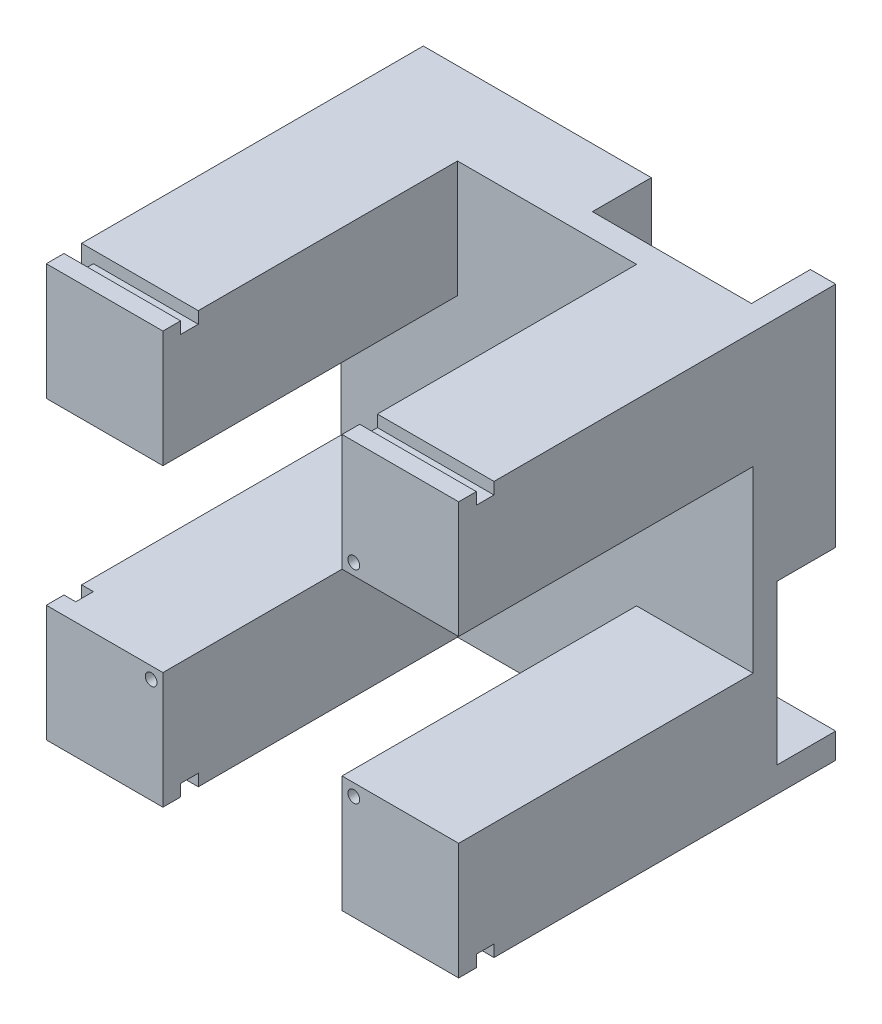
from build123d import *

# Parameters (mm, degrees)
ESQUISSE1_W                  = 70
ESQUISSE1_H                  = 70
BOSS_EXTRU_1_DEPTH           = 64
ESQUISSE2_W                  = 30.4
ESQUISSE2_H                  = 19.8
ESQUISSE2_H_2                = 30.4
ESQUISSE2_W_2                = 19.8
ENL_V_MAT_EXTRU_1_DEPTH      = 50
ESQUISSE5_W                  = 3
ESQUISSE5_H                  = 2
ENL_V_MAT_EXTRU_3_DEPTH      = 71
ESQUISSE6_W                  = 2
ESQUISSE6_H                  = 3
ENL_V_MAT_EXTRU_4_DEPTH      = 71
ESQUISSE7_R                  = 1
ENL_V_MAT_EXTRU_5_DEPTH      = 65
ENL_V_MAT_EXTRU_7_DEPTH      = 10
BOSS_EXTRU_2_DEPTH           = 3.8
ESQUISSE10_W                 = 27
ESQUISSE10_H                 = 18.1
ENL_V_MAT_EXTRU_8_DEPTH      = 10
ESQUISSE11_R                 = 1.25
ENL_V_MAT_EXTRU_9_DEPTH      = 15
R_P_TITION_CIRCULAIRE1_COUNT = 3
R_P_TITION_CIRCULAIRE1_ANGLE = 180


with BuildPart() as part:
    # Esquisse1 → Boss.-Extru.1 (new body)
    with BuildSketch(Plane.XY):
        with Locations((-35, 35)):
            Rectangle(ESQUISSE1_W, ESQUISSE1_H)
    extrude(amount=BOSS_EXTRU_1_DEPTH)

    # Esquisse2 → Enlèv. mat.-Extru.1 (cut)
    with BuildSketch(Plane.XY.offset(64)):
        with Locations((-35, 60.1)):
            Rectangle(ESQUISSE2_W, ESQUISSE2_H)
        with Locations((-35, 35)):
            Rectangle(ESQUISSE2_W, ESQUISSE2_H_2)
        with Locations((-9.9, 35)):
            Rectangle(ESQUISSE2_W_2, ESQUISSE2_H_2)
        with Locations((-60.1, 35)):
            Rectangle(ESQUISSE2_W_2, ESQUISSE2_H_2)
        with Locations((-35, 9.9)):
            Rectangle(ESQUISSE2_W, ESQUISSE2_H)
    extrude(amount=-ENL_V_MAT_EXTRU_1_DEPTH, mode=Mode.SUBTRACT)

    # Esquisse5 → Enlèv. mat.-Extru.3 (cut, through all)
    with BuildSketch(Plane.ZY.offset(70)):
        with Locations((59.5, 69)):
            Rectangle(ESQUISSE5_W, ESQUISSE5_H)
        with Locations((59.5, 1)):
            Rectangle(ESQUISSE5_W, ESQUISSE5_H)
    extrude(amount=-ENL_V_MAT_EXTRU_3_DEPTH, mode=Mode.SUBTRACT)

    # Esquisse6 → Enlèv. mat.-Extru.4 (cut, through all)
    with BuildSketch(Plane(origin=(0, 70, 0), x_dir=(1, 0, 0), z_dir=(0, 1, 0))):
        with Locations((-69, -59.5)):
            Rectangle(ESQUISSE6_W, ESQUISSE6_H)
    extrude(amount=-ENL_V_MAT_EXTRU_4_DEPTH, mode=Mode.SUBTRACT)

    # Esquisse7 → Enlèv. mat.-Extru.5 (cut, through all)
    with BuildSketch(Plane.XY.offset(64)):
        with Locations((-52.2, 17.8)):
            Circle(ESQUISSE7_R)
    enl_v_mat_extru_5 = extrude(amount=-ENL_V_MAT_EXTRU_5_DEPTH, mode=Mode.SUBTRACT)

    # Esquisse8 → Enlèv. mat.-Extru.7 (cut)
    with BuildSketch(Plane(origin=(0, 0, 0), x_dir=(-1, 0, 0), z_dir=(0, 0, -1))):
        with BuildLine():
            Line((60.2, 0), (60.2, 17.8))
            ThreePointArc((60.2, 17.8), (52.2, 9.8), (44.2, 17.8))
            Line((44.2, 17.8), (44.2, 0))
            Line((44.2, 0), (60.2, 0))
        make_face()
        with BuildLine():
            ThreePointArc((44.2, 17.8), (52.2, 9.8), (60.2, 17.8))
            Line((60.2, 17.8), (53.2, 17.8))
            ThreePointArc((53.2, 17.8), (52.2, 16.8), (51.2, 17.8))
            Line((51.2, 17.8), (44.2, 17.8))
        make_face()
        with BuildLine():
            Line((53.2, 17.8), (60.2, 17.8))
            ThreePointArc((60.2, 17.8), (52.2, 25.8), (44.2, 17.8))
            Line((44.2, 17.8), (51.2, 17.8))
            ThreePointArc((51.2, 17.8), (52.2, 18.8), (53.2, 17.8))
        make_face()
    enl_v_mat_extru_7 = extrude(amount=-ENL_V_MAT_EXTRU_7_DEPTH, mode=Mode.SUBTRACT)

    # Esquisse9 → Boss.-Extru.2 (add)
    with BuildSketch(Plane(origin=(0, 0, 0), x_dir=(-1, 0, 0), z_dir=(0, 0, -1))):
        with BuildLine():
            Line((46.2, 0), (46.2, 17.8))
            ThreePointArc((46.2, 17.8), (52.2, 23.8), (58.2, 17.8))
            Line((58.2, 17.8), (58.2, 0))
            Line((58.2, 0), (60.2, 0))
            Line((60.2, 0), (60.2, 17.8))
            Line((60.2, 17.8), (60.175717696, 28.742363645))
            Line((60.175717696, 28.742363645), (44.2, 28.742363645))
            Line((44.2, 28.742363645), (44.2, 0))
            Line((44.2, 0), (46.2, 0))
        make_face()
    extrude(amount=-BOSS_EXTRU_2_DEPTH)

    # Esquisse10 → Enlèv. mat.-Extru.8 (cut)
    with BuildSketch(Plane(origin=(0, 0, 0), x_dir=(-1, 0, 0), z_dir=(0, 0, -1))):
        with Locations((52.2, 9.05)):
            Rectangle(ESQUISSE10_W, ESQUISSE10_H)
    enl_v_mat_extru_8 = extrude(amount=-ENL_V_MAT_EXTRU_8_DEPTH, mode=Mode.SUBTRACT)

    # Esquisse11 → Enlèv. mat.-Extru.9 (cut)
    with BuildSketch(Plane.XZ.offset(-18.1)):
        with Locations(Location((-41.7, 7, 0), (0, 0, 270))):  # turned: the seam where the file's is
            Circle(ESQUISSE11_R)
        with Locations(Location((-62.7, 7, 0), (0, 0, 270))):  # turned: the seam where the file's is
            Circle(ESQUISSE11_R)
    extrude(amount=-ENL_V_MAT_EXTRU_9_DEPTH, mode=Mode.SUBTRACT)

    # Répétition circulaire1: Enlèv. mat.-Extru.5, Enlèv. mat.-Extru.7, Enlèv. mat.-Extru.8 ×3 about axis
    r_p_tition_circulaire1_axis = Axis((-35, 35, 0), (0, 0, 1))
    add([enl_v_mat_extru_5.rotate(r_p_tition_circulaire1_axis, i * R_P_TITION_CIRCULAIRE1_ANGLE / (R_P_TITION_CIRCULAIRE1_COUNT - 1)) for i in range(1, R_P_TITION_CIRCULAIRE1_COUNT)], mode=Mode.SUBTRACT)
    add([enl_v_mat_extru_7.rotate(r_p_tition_circulaire1_axis, i * R_P_TITION_CIRCULAIRE1_ANGLE / (R_P_TITION_CIRCULAIRE1_COUNT - 1)) for i in range(1, R_P_TITION_CIRCULAIRE1_COUNT)], mode=Mode.SUBTRACT)
    add([enl_v_mat_extru_8.rotate(r_p_tition_circulaire1_axis, i * R_P_TITION_CIRCULAIRE1_ANGLE / (R_P_TITION_CIRCULAIRE1_COUNT - 1)) for i in range(1, R_P_TITION_CIRCULAIRE1_COUNT)], mode=Mode.SUBTRACT)


solid = part.part
